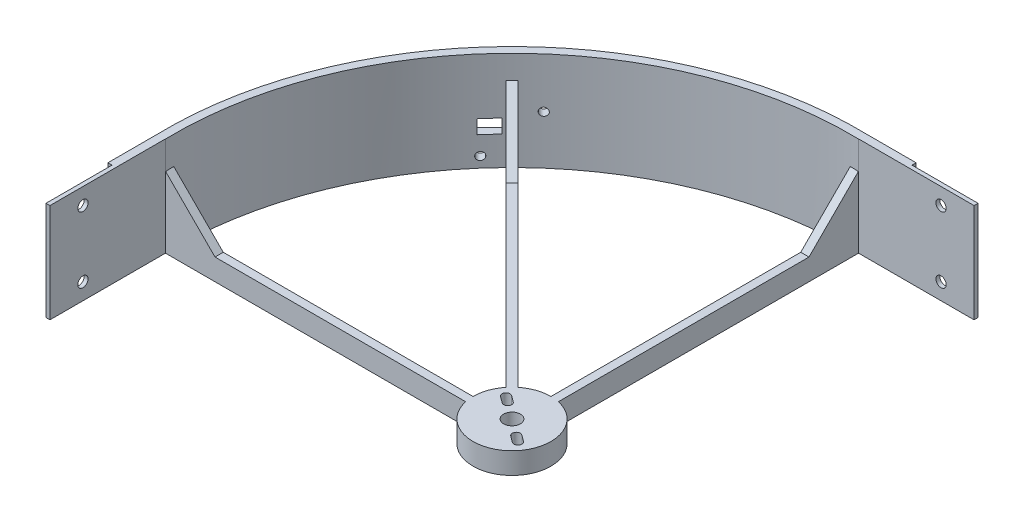
from build123d import *

# Parameters (mm, degrees)
SKETCH1_R            = 15
BOSS_EXTRUDE2_DEPTH  = 8.255
BOSS_EXTRUDE3_DEPTH  = 8.255
BOSS_EXTRUDE4_DEPTH  = 38.1
SKETCH5_R            = 3.249999977
CUT_EXTRUDE3_DEPTH   = 63.5
BOSS_EXTRUDE9_DEPTH  = 3.175
BOSS_EXTRUDE11_DEPTH = 3.175
BOSS_EXTRUDE14_DEPTH = 3.175
SKETCH15_W           = 38.1
SKETCH15_H           = 44.45
BOSS_EXTRUDE15_DEPTH = 1.524
SKETCH16_W           = 38.1
SKETCH16_H           = 44.45
BOSS_EXTRUDE16_DEPTH = 1.524
SKETCH17_R           = 1.98501
CUT_EXTRUDE4_DEPTH   = 2.54
SKETCH18_R           = 1.98501
CUT_EXTRUDE5_DEPTH   = 2.54
SKETCH19_W           = 19.05
SKETCH19_H           = 38.1
BOSS_EXTRUDE17_DEPTH = 1.587961
SKETCH20_W           = 19.05
SKETCH20_H           = 38.1
BOSS_EXTRUDE18_DEPTH = 1.587961
CUT_EXTRUDE6_REACH   = 202.702
SKETCH21_R           = 1.524
BOSS_EXTRUDE20_START = -0.60614
SKETCH21_3_W         = 25.4
SKETCH21_3_H         = 22.86
SKETCH21_3_R         = 1.524
BOSS_EXTRUDE20_DEPTH = 0.60614
CUT_EXTRUDE7_REACH   = 202.702
SKETCH26_W           = 6.858
SKETCH26_H           = 5.334


with BuildPart() as part:
    # Sketch1 → Boss-Extrude2 (new body)
    with BuildSketch(Plane(origin=(0, 0, 0), x_dir=(1, 0, 0), z_dir=(0, 1, 0))):
        Circle(SKETCH1_R)
    extrude(amount=BOSS_EXTRUDE2_DEPTH)

    # Sketch1_6 → Boss-Extrude3 (add)
    with BuildSketch(Plane(origin=(0, 0, 0), x_dir=(1, 0, 0), z_dir=(0, 1, 0))):
        with BuildLine():
            ThreePointArc((3.175, 130.136274728), (1.587618078, 130.165318322), (0, 130.175))
            Line((0, 130.175), (0, 15))
            ThreePointArc((0, 15), (1.596569562, 14.914790164), (3.175, 14.660128751))
            Line((3.175, 14.660128751), (3.175, 130.136274728))
        make_face()
        with BuildLine():
            Line((-9.42450178, 11.66956581), (-90.918248264, 93.163312294))
            ThreePointArc((-90.918248264, 93.163312294), (-92.047625241, 92.047625241), (-93.163312294, 90.918248264))
            Line((-93.163312294, 90.918248264), (-11.66956581, 9.42450178))
            ThreePointArc((-11.66956581, 9.42450178), (-10.606601718, 10.606601718), (-9.42450178, 11.66956581))
        make_face()
        with BuildLine():
            Line((-15, 0), (-130.175, 0))
            ThreePointArc((-130.175, 0), (-130.165318322, -1.587618078), (-130.136274728, -3.175))
            Line((-130.136274728, -3.175), (-14.660128751, -3.175))
            ThreePointArc((-14.660128751, -3.175), (-14.914790164, -1.596569562), (-15, 0))
        make_face()
    extrude(amount=BOSS_EXTRUDE3_DEPTH)

    # Sketch1_7 → Boss-Extrude4 (add)
    with BuildSketch(Plane(origin=(0, 0, 0), x_dir=(1, 0, 0), z_dir=(0, 1, 0))):
        with BuildLine():
            Line((3.175, 130.136274728), (3.175, 133.312197023))
            ThreePointArc((3.175, 133.312197023), (-94.292689271, 94.292689271), (-133.312197023, -3.175))
            Line((-133.312197023, -3.175), (-130.136274728, -3.175))
            ThreePointArc((-130.136274728, -3.175), (-92.047625241, 92.047625241), (3.175, 130.136274728))
        make_face()
    extrude(amount=BOSS_EXTRUDE4_DEPTH)

    # Sketch5 → Cut-Extrude3 (cut)
    with BuildSketch(Plane(origin=(0, 8.255, 0), x_dir=(1, 0, 0), z_dir=(0, 1, 0))):
        Circle(SKETCH5_R)
        with BuildLine():
            Line((-7.236078848, 3.458556767), (-9.686234559, 5.271576621))
            ThreePointArc((-9.686234559, 5.271576621), (-10.004802487, 7.403164404), (-7.873214705, 7.721732332))
            Line((-7.873214705, 7.721732332), (-5.423058993, 5.908712478))
            ThreePointArc((-5.423058993, 5.908712478), (-5.104491065, 3.777124696), (-7.236078848, 3.458556767))
        make_face()
        with BuildLine():
            Line((5.423058993, -5.908712478), (7.873214705, -7.721732332))
            ThreePointArc((7.873214705, -7.721732332), (10.004802487, -7.403164404), (9.686234559, -5.271576621))
            Line((9.686234559, -5.271576621), (7.236078848, -3.458556767))
            ThreePointArc((7.236078848, -3.458556767), (5.104491065, -3.777124696), (5.423058993, -5.908712478))
        make_face()
    extrude(amount=-CUT_EXTRUDE3_DEPTH, mode=Mode.SUBTRACT)

    # Sketch10 → Boss-Extrude9 (add)
    with BuildSketch(Plane(origin=(0, 0, 0), x_dir=(-1, 0, 0), z_dir=(0, 0, -1))):
        Polygon((130.175, 27.305), (130.175, 8.255), (111.125, 8.255), align=None)
    extrude(amount=-BOSS_EXTRUDE9_DEPTH)

    # Sketch13 → Boss-Extrude11 (add)
    with BuildSketch(Plane.ZY):
        Polygon((-130.175, 27.305), (-111.125, 8.255), (-130.175, 8.255), align=None)
    extrude(amount=-BOSS_EXTRUDE11_DEPTH)

    # Sketch14 → Boss-Extrude14 (add)
    with BuildSketch(Plane(origin=(1.122532015, 0, -1.122532015), x_dir=(-0.707106781, 0, -0.707106781), z_dir=(0.707106781, 0, -0.707106781))):
        Polygon((133.340319762, 8.255), (111.115319762, 8.255), (133.340319762, 32.394680238), align=None)
    extrude(amount=-BOSS_EXTRUDE14_DEPTH)

    # Sketch15 → Boss-Extrude15 (add)
    with BuildSketch(Plane(origin=(-131.724235875, 0, 0), x_dir=(0, -1, 0), z_dir=(-1, 0, 0))):
        with Locations((-19.05, 25.4)):
            Rectangle(SKETCH15_W, SKETCH15_H)
    extrude(amount=-BOSS_EXTRUDE15_DEPTH)

    # Sketch16 → Boss-Extrude16 (add)
    with BuildSketch(Plane(origin=(0, 0, -131.724235875), x_dir=(0, -1, 0), z_dir=(0, 0, -1))):
        with Locations((-19.05, -25.4)):
            Rectangle(SKETCH16_W, SKETCH16_H)
    extrude(amount=-BOSS_EXTRUDE16_DEPTH)

    # Sketch17 → Cut-Extrude4 (cut)
    with BuildSketch(Plane(origin=(0, 0, -131.724235875), x_dir=(-1, 0, 0), z_dir=(0, 0, -1))):
        with Locations((-34.925, 31.75)):
            Circle(SKETCH17_R)
        with Locations((-34.925, 6.35)):
            Circle(SKETCH17_R)
    extrude(amount=-CUT_EXTRUDE4_DEPTH, mode=Mode.SUBTRACT)

    # Sketch18 → Cut-Extrude5 (cut)
    with BuildSketch(Plane.ZY.offset(131.724235875)):
        with Locations((34.925, 31.75)):
            Circle(SKETCH18_R)
        with Locations((34.925, 6.35)):
            Circle(SKETCH18_R)
    extrude(amount=-CUT_EXTRUDE5_DEPTH, mode=Mode.SUBTRACT)

    # Sketch19 → Boss-Extrude17 (add)
    with BuildSketch(Plane.ZY.offset(131.724235875)):
        with Locations((12.7, 19.05)):
            Rectangle(SKETCH19_W, SKETCH19_H)
    extrude(amount=BOSS_EXTRUDE17_DEPTH)

    # Sketch20 → Boss-Extrude18 (add)
    with BuildSketch(Plane(origin=(0, 0, -131.724235875), x_dir=(-1, 0, 0), z_dir=(0, 0, -1))):
        with Locations((-12.7, 19.05)):
            Rectangle(SKETCH20_W, SKETCH20_H)
    extrude(amount=BOSS_EXTRUDE18_DEPTH)

    # Sketch21 → Cut-Extrude6 (cut, up to next)
    with BuildSketch(Plane(origin=(-94.292689271, 0, -94.292689271), x_dir=(-0.707106781, 0, 0.707106781), z_dir=(-0.707106781, 0, -0.707106781)), mode=Mode.PRIVATE) as cut_extrude6_sk1:
        with Locations((8.636, 4.064)):
            Circle(SKETCH21_R)
    cut_extrude6_tool1 = extrude(cut_extrude6_sk1.sketch, amount=-CUT_EXTRUDE6_REACH, mode=Mode.PRIVATE) & part.part
    add(cut_extrude6_tool1.solids().sort_by_distance((-100.399263, 4.064, -88.186115))[0], mode=Mode.SUBTRACT)
    # Sketch21 → Cut-Extrude6 (cut, up to next)
    with BuildSketch(Plane(origin=(-94.292689271, 0, -94.292689271), x_dir=(-0.707106781, 0, 0.707106781), z_dir=(-0.707106781, 0, -0.707106781)), mode=Mode.PRIVATE) as cut_extrude6_sk2:
        with Locations((-8.636, 18.796)):
            Circle(SKETCH21_R)
    cut_extrude6_tool2 = extrude(cut_extrude6_sk2.sketch, amount=-CUT_EXTRUDE6_REACH, mode=Mode.PRIVATE) & part.part
    add(cut_extrude6_tool2.solids().sort_by_distance((-88.186115, 18.796, -100.399263))[0], mode=Mode.SUBTRACT)

    # Sketch21_3 → Boss-Extrude20 (add)
    with BuildSketch(Plane(origin=(-94.292689271, 0, -94.292689271), x_dir=(-0.707106781, 0, 0.707106781), z_dir=(-0.707106781, 0, -0.707106781)).offset(BOSS_EXTRUDE20_START)):
        with Locations((0, 11.43)):
            Rectangle(SKETCH21_3_W, SKETCH21_3_H)
        with Locations((8.636, 4.064)):
            Circle(SKETCH21_3_R, mode=Mode.SUBTRACT)
        with Locations((-8.636, 18.796)):
            Circle(SKETCH21_3_R, mode=Mode.SUBTRACT)
    extrude(amount=BOSS_EXTRUDE20_DEPTH)

    # Sketch26 → Cut-Extrude7 (cut, up to next)
    with BuildSketch(Plane(origin=(-94.292689271, 0, -94.292689271), x_dir=(-0.707106781, 0, 0.707106781), z_dir=(-0.707106781, 0, -0.707106781)), mode=Mode.PRIVATE) as cut_extrude7_sk1:
        with Locations((6.096, 13.843)):
            Rectangle(SKETCH26_W, SKETCH26_H)
    cut_extrude7_tool1 = extrude(cut_extrude7_sk1.sketch, amount=-CUT_EXTRUDE7_REACH, mode=Mode.PRIVATE) & part.part
    add(cut_extrude7_tool1.solids().sort_by_distance((-98.603212, 13.843, -89.982166))[0], mode=Mode.SUBTRACT)


solid = part.part
